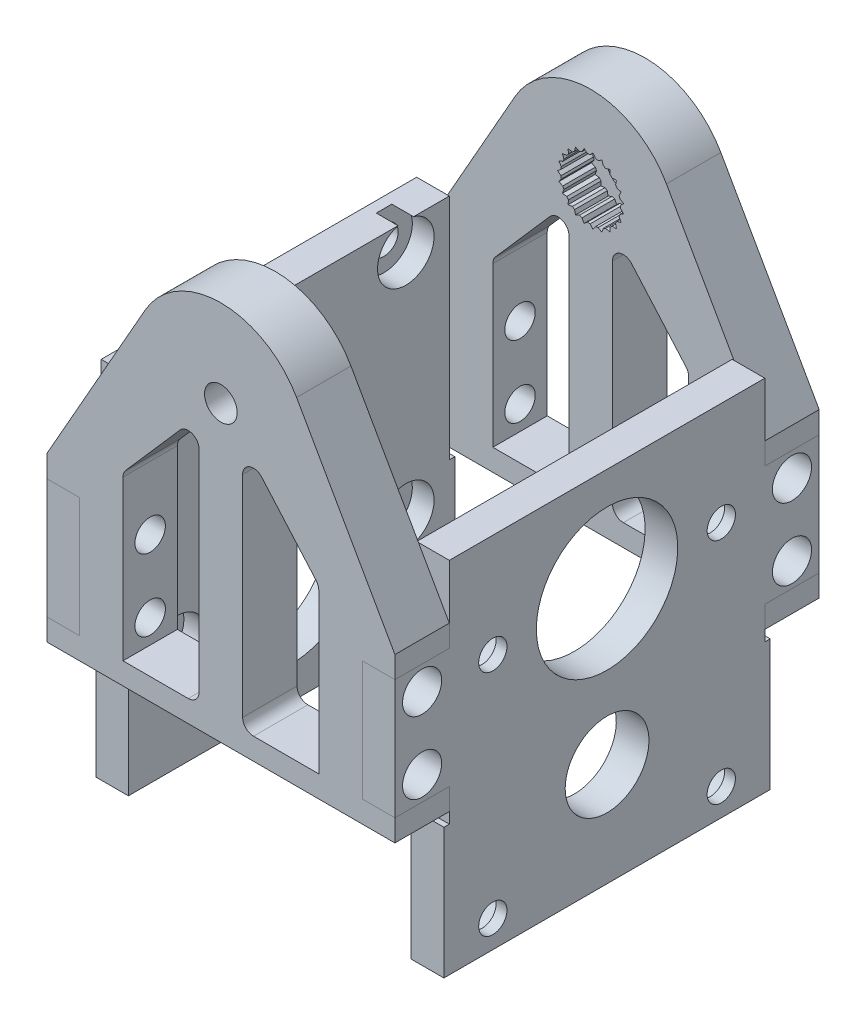
from build123d import *

# Parameters (mm, degrees)
SKETCH_1_R                       = 2.75
EXTRUDE_1_DEPTH                  = 3
CUT_EXTRUDE_6_DEPTH              = 4
EXTRUDE_2_DEPTH                  = 2
SKETCH_3_R                       = 3.6
EXTRUDE_3_DEPTH                  = 1.5
EXTRUDE_4_DEPTH                  = 3.5
SKETCH_5_W                       = 3
SKETCH_5_H                       = 11
CUT_EXTRUDE_1_DEPTH              = 40
SKETCH_6_R                       = 6.5
SKETCH_6_R_2                     = 1.3
SKETCH_6_R_3                     = 3.85
EXTRUDE_5_DEPTH                  = 3
SKETCH_8_R                       = 1.3
SKETCH_8_R_2                     = 6.5
SKETCH_8_R_3                     = 3.85
EXTRUDE_6_DEPTH                  = 3
SKETCH_7_R                       = 1.5
CUT_EXTRUDE_2_DEPTH              = 40
HOLE_WIZARD_2_8_2_8_1_AT_2_COUNT = 2
HOLE_WIZARD_2_8_2_8_1_AT_2_PITCH = 34.634664716
HOLE_WIZARD_2_8_2_8_1_AT_3_COUNT = 2
HOLE_WIZARD_2_8_2_8_1_AT_3_PITCH = 34
HOLE_WIZARD_2_8_2_8_1_AT_4_COUNT = 2
HOLE_WIZARD_2_8_2_8_1_AT_4_PITCH = 6.6
HOLE_WIZARD_2_8_2_8_2_AT_2_COUNT = 2
HOLE_WIZARD_2_8_2_8_2_AT_2_PITCH = 6.6
HOLE_WIZARD_2_8_2_8_2_AT_3_COUNT = 2
HOLE_WIZARD_2_8_2_8_2_AT_3_PITCH = 34
HOLE_WIZARD_2_8_2_8_2_AT_4_COUNT = 2
HOLE_WIZARD_2_8_2_8_2_AT_4_PITCH = 34.634664716
SKETCH_16_W                      = 1.8
SKETCH_16_H                      = 32
HOLE_WIZARD_3_6_3_6_1_AT_2_COUNT = 2
HOLE_WIZARD_3_6_3_6_1_AT_2_PITCH = 6.6
HOLE_WIZARD_3_6_3_6_1_AT_3_COUNT = 2
HOLE_WIZARD_3_6_3_6_1_AT_3_PITCH = 34
HOLE_WIZARD_3_6_3_6_1_AT_4_COUNT = 2
HOLE_WIZARD_3_6_3_6_1_AT_4_PITCH = 34.634664716
SKETCH_17_R                      = 2.6
CUT_EXTRUDE_4_DEPTH              = 2
SKETCH_18_R                      = 2.6
CUT_EXTRUDE_5_DEPTH              = 2
SKETCH_20_W                      = 3
SKETCH_20_H                      = 12
EXTRUDE_7_DEPTH                  = 0.5
SKETCH_21_W                      = 3
SKETCH_21_H                      = 12
EXTRUDE_8_DEPTH                  = 0.5
SKETCH_22_R                      = 4.2
CUT_EXTRUDE_7_DEPTH              = 4


with BuildPart() as part:
    # ｽｹｯﾁ1 → ﾎﾞｽ - 押し出し1 (new body)
    with BuildSketch(Plane.XY):
        with BuildLine():
            Line((-16, -12), (-16, -27))
            Line((-16, -27), (16, -27))
            Line((16, -27), (16, -12))
            Line((16, -12), (6.959272667, 3.94569689))
            ThreePointArc((6.959272667, 3.94569689), (0, 8), (-6.959272667, 3.94569689))
            Line((-6.959272667, 3.94569689), (-16, -12))
        make_face()
        Circle(SKETCH_1_R, mode=Mode.SUBTRACT)
    extrude(amount=EXTRUDE_1_DEPTH)

    # ｽｹｯﾁ19 → ｶｯﾄ - 押し出し6 (cut, through all)
    with BuildSketch(Plane.XY.offset(3)):
        with BuildLine():
            Line((0.208139361, 3.042889746), (-0.062598794, 2.749287433))
            ThreePointArc((-0.062598794, 2.749287433), (0.187666637, 2.743589115), (0.436377003, 2.715156554))
            Line((0.436377003, 2.715156554), (0.208139361, 3.042889746))
        make_face()
        with BuildLine():
            Line((1.021382817, 2.873895812), (0.681471411, 2.66422535))
            ThreePointArc((0.681471411, 2.66422535), (0.920918933, 2.591217536), (1.152735431, 2.496738077))
            Line((1.152735431, 2.496738077), (1.021382817, 2.873895812))
        make_face()
        with BuildLine():
            Line((1.758874982, 2.491758174), (1.375, 2.38156986))
            ThreePointArc((1.375, 2.38156986), (1.585870886, 2.246667206), (1.783600746, 2.093147959))
            Line((1.783600746, 2.093147959), (1.758874982, 2.491758174))
        make_face()
        with BuildLine():
            Line((2.365919437, 1.92481823), (1.966551129, 1.922284229))
            ThreePointArc((1.966551129, 1.922284229), (2.133206049, 1.735491847), (2.282184553, 1.534318633))
            Line((2.282184553, 1.534318633), (2.365919437, 1.92481823))
        make_face()
        with BuildLine():
            Line((2.79749447, 1.215123324), (2.412252157, 1.320431571))
            ThreePointArc((2.412252157, 1.320431571), (2.522331079, 1.095602997), (2.611509172, 0.861695912))
            Line((2.611509172, 0.861695912), (2.79749447, 1.215123324))
        make_face()
        with BuildLine():
            Line((3.021592135, 0.41530828), (2.679047477, 0.620648543))
            ThreePointArc((2.679047477, 0.620648543), (2.724386352, 0.374458285), (2.747150103, 0.125165148))
            Line((2.747150103, 0.125165148), (3.021592135, 0.41530828))
        make_face()
        with BuildLine():
            Line((3.021592135, -0.41530828), (2.747150103, -0.125165148))
            ThreePointArc((2.747150103, -0.125165148), (2.724386352, -0.374458285), (2.679047477, -0.620648543))
            Line((2.679047477, -0.620648543), (3.021592135, -0.41530828))
        make_face()
        with BuildLine():
            Line((2.79749447, -1.215123324), (2.611509172, -0.861695912))
            ThreePointArc((2.611509172, -0.861695912), (2.522331079, -1.095602997), (2.412252157, -1.320431571))
            Line((2.412252157, -1.320431571), (2.79749447, -1.215123324))
        make_face()
        with BuildLine():
            Line((2.365919437, -1.92481823), (2.282184553, -1.534318633))
            ThreePointArc((2.282184553, -1.534318633), (2.133206049, -1.735491847), (1.966551129, -1.922284229))
            Line((1.966551129, -1.922284229), (2.365919437, -1.92481823))
        make_face()
        with BuildLine():
            Line((1.758874982, -2.491758174), (1.783600746, -2.093147959))
            ThreePointArc((1.783600746, -2.093147959), (1.585870886, -2.246667206), (1.375, -2.38156986))
            Line((1.375, -2.38156986), (1.758874982, -2.491758174))
        make_face()
        with BuildLine():
            Line((1.021382817, -2.873895812), (1.152735431, -2.496738077))
            ThreePointArc((1.152735431, -2.496738077), (0.920918933, -2.591217536), (0.681471411, -2.66422535))
            Line((0.681471411, -2.66422535), (1.021382817, -2.873895812))
        make_face()
        with BuildLine():
            Line((0.208139361, -3.042889746), (0.436377003, -2.715156554))
            ThreePointArc((0.436377003, -2.715156554), (0.187666637, -2.743589115), (-0.062598794, -2.749287433))
            Line((-0.062598794, -2.749287433), (0.208139361, -3.042889746))
        make_face()
        with BuildLine():
            Line((-0.62054084, -2.986206467), (-0.312345512, -2.73220429))
            ThreePointArc((-0.312345512, -2.73220429), (-0.559504036, -2.692481241), (-0.802026334, -2.630447445))
            Line((-0.802026334, -2.630447445), (-0.62054084, -2.986206467))
        make_face()
        with BuildLine():
            Line((-1.403198365, -2.708049916), (-1.037902788, -2.546616933))
            ThreePointArc((-1.037902788, -2.546616933), (-1.265178854, -2.441684351), (-1.481971249, -2.316519203))
            Line((-1.481971249, -2.316519203), (-1.403198365, -2.708049916))
        make_face()
        with BuildLine():
            Line((-2.081787087, -2.229049691), (-1.686483563, -2.172158648))
            ThreePointArc((-1.686483563, -2.172158648), (-1.877021144, -2.009798902), (-2.052005136, -1.830785329))
            Line((-2.052005136, -1.830785329), (-2.081787087, -2.229049691))
        make_face()
        with BuildLine():
            Line((-2.605979184, -1.584731048), (-2.209985568, -1.636601293))
            ThreePointArc((-2.209985568, -1.636601293), (-2.349653363, -1.428855863), (-2.46985119, -1.209270483))
            Line((-2.46985119, -1.209270483), (-2.605979184, -1.584731048))
        make_face()
        with BuildLine():
            Line((-2.936897726, -0.822880152), (-2.569583052, -0.979664707))
            ThreePointArc((-2.569583052, -0.979664707), (-2.64802254, -0.741941121), (-2.704519679, -0.498069577))
            Line((-2.704519679, -0.498069577), (-2.936897726, -0.822880152))
        make_face()
        with BuildLine():
            Line((-3.05, 0), (-2.738606317, -0.250070871))
            ThreePointArc((-2.738606317, -0.250070871), (-2.75, 0), (-2.738606317, 0.250070871))
            Line((-2.738606317, 0.250070871), (-3.05, 0))
        make_face()
        with BuildLine():
            Line((-2.936897726, 0.822880152), (-2.704519679, 0.498069577))
            ThreePointArc((-2.704519679, 0.498069577), (-2.64802254, 0.741941121), (-2.569583052, 0.979664707))
            Line((-2.569583052, 0.979664707), (-2.936897726, 0.822880152))
        make_face()
        with BuildLine():
            Line((-2.605979184, 1.584731048), (-2.46985119, 1.209270483))
            ThreePointArc((-2.46985119, 1.209270483), (-2.349653363, 1.428855863), (-2.209985568, 1.636601293))
            Line((-2.209985568, 1.636601293), (-2.605979184, 1.584731048))
        make_face()
        with BuildLine():
            Line((-2.081787087, 2.229049691), (-2.052005136, 1.830785329))
            ThreePointArc((-2.052005136, 1.830785329), (-1.877021144, 2.009798902), (-1.686483563, 2.172158648))
            Line((-1.686483563, 2.172158648), (-2.081787087, 2.229049691))
        make_face()
        with BuildLine():
            Line((-1.403198365, 2.708049916), (-1.481971249, 2.316519203))
            ThreePointArc((-1.481971249, 2.316519203), (-1.265178854, 2.441684351), (-1.037902788, 2.546616933))
            Line((-1.037902788, 2.546616933), (-1.403198365, 2.708049916))
        make_face()
        with BuildLine():
            Line((-0.62054084, 2.986206467), (-0.802026334, 2.630447445))
            ThreePointArc((-0.802026334, 2.630447445), (-0.559504036, 2.692481241), (-0.312345512, 2.73220429))
            Line((-0.312345512, 2.73220429), (-0.62054084, 2.986206467))
        make_face()
    extrude(amount=-CUT_EXTRUDE_6_DEPTH, mode=Mode.SUBTRACT)

    # ｽｹｯﾁ2 → ﾎﾞｽ - 押し出し2 (add)
    with BuildSketch(Plane(origin=(0, 0, 0), x_dir=(-1, 0, 0), z_dir=(0, 0, -1))):
        with BuildLine():
            Line((16, -12), (6.959272667, 3.94569689))
            ThreePointArc((6.959272667, 3.94569689), (0, 8), (-6.959272667, 3.94569689))
            Line((-6.959272667, 3.94569689), (-16, -12))
            Line((-16, -12), (-16, -27))
            Line((-16, -27), (16, -27))
            Line((16, -27), (16, -12))
        make_face()
    extrude(amount=EXTRUDE_2_DEPTH)


with BuildPart() as body_2:
    # ｽｹｯﾁ3 → ﾎﾞｽ - 押し出し3 (new body)
    with BuildSketch(Plane.XY.offset(33.5)):
        with BuildLine():
            Line((-6.959272667, 3.94569689), (-16, -12))
            Line((-16, -12), (-16, -27))
            Line((-16, -27), (16, -27))
            Line((16, -27), (16, -12))
            Line((16, -12), (6.959272667, 3.94569689))
            ThreePointArc((6.959272667, 3.94569689), (0, 8), (-6.959272667, 3.94569689))
        make_face()
        Circle(SKETCH_3_R, mode=Mode.SUBTRACT)
    extrude(amount=-EXTRUDE_3_DEPTH)

    # ｽｹｯﾁ4 → ﾎﾞｽ - 押し出し4 (add)
    with BuildSketch(Plane.XY.offset(33.5)):
        with BuildLine():
            Line((-6.959272667, 3.94569689), (-16, -12))
            Line((-16, -12), (-16, -27))
            Line((-16, -27), (16, -27))
            Line((16, -27), (16, -12))
            Line((16, -12), (6.959272667, 3.94569689))
            ThreePointArc((6.959272667, 3.94569689), (0, 8), (-6.959272667, 3.94569689))
        make_face()
    extrude(amount=EXTRUDE_4_DEPTH)


with BuildPart() as cut_extrude_1_tool:
    # ｽｹｯﾁ5 → ｶｯﾄ - 押し出し1 (new body, through all)
    with BuildSketch(Plane(origin=(0, 0, -2), x_dir=(-1, 0, 0), z_dir=(0, 0, -1))):
        with Locations((-14.5, -19.5)):
            Rectangle(SKETCH_5_W, SKETCH_5_H)
        with Locations((14.5, -19.5)):
            Rectangle(SKETCH_5_W, SKETCH_5_H)
    extrude(amount=-CUT_EXTRUDE_1_DEPTH)


with BuildPart() as part_1:
    add(part.part)

    # ｶｯﾄ - 押し出し1: cut by cut_extrude_1_tool
    add(cut_extrude_1_tool.part, mode=Mode.SUBTRACT)


with BuildPart() as body_2_1:
    add(body_2.part)

    # ｶｯﾄ - 押し出し1: cut by cut_extrude_1_tool
    add(cut_extrude_1_tool.part, mode=Mode.SUBTRACT)


with BuildPart() as body_3:
    # ｽｹｯﾁ6 → ﾎﾞｽ - 押し出し5 (new body)
    with BuildSketch(Plane(origin=(13, 0, 0), x_dir=(0, 0, -1), z_dir=(1, 0, 0))):
        Polygon((2, -14), (-3, -14), (-3, -7), (-32, -7), (-32, -14), (-37, -14), (-37, -25), (-32, -25), (-32, -40), (-3, -40), (-3, -25), (2, -25), align=None)
        with Locations((-17.5, -16.5)):
            Circle(SKETCH_6_R, mode=Mode.SUBTRACT)
        with Locations((-28, -16.5)):
            Circle(SKETCH_6_R_2, mode=Mode.SUBTRACT)
        with Locations((-7, -16.5)):
            Circle(SKETCH_6_R_2, mode=Mode.SUBTRACT)
        with Locations((-28, -37.5)):
            Circle(SKETCH_6_R_2, mode=Mode.SUBTRACT)
        with Locations((-7, -37.5)):
            Circle(SKETCH_6_R_2, mode=Mode.SUBTRACT)
        with Locations((-17.5, -30.5)):
            Circle(SKETCH_6_R_3, mode=Mode.SUBTRACT)
    extrude(amount=EXTRUDE_5_DEPTH)


with BuildPart() as body_4:
    # ｽｹｯﾁ8 → ﾎﾞｽ - 押し出し6 (new body)
    with BuildSketch(Plane.ZY.offset(13)):
        Polygon((-2, -14), (-2, -25), (3, -25), (3, -40), (32, -40), (32, -25), (37, -25), (37, -14), (32, -14), (32, -7), (3, -7), (3, -14), align=None)
        with Locations((28, -9.5)):
            Circle(SKETCH_8_R, mode=Mode.SUBTRACT)
        with Locations((7, -9.5)):
            Circle(SKETCH_8_R, mode=Mode.SUBTRACT)
        with Locations((28, -30.5)):
            Circle(SKETCH_8_R, mode=Mode.SUBTRACT)
        with Locations((17.5, -30.5)):
            Circle(SKETCH_8_R_2, mode=Mode.SUBTRACT)
        with Locations((7, -30.5)):
            Circle(SKETCH_8_R, mode=Mode.SUBTRACT)
        with Locations((17.5, -16.5)):
            Circle(SKETCH_8_R_3, mode=Mode.SUBTRACT)
    extrude(amount=EXTRUDE_6_DEPTH)


with BuildPart() as cut_extrude_2_tool:
    # ｽｹｯﾁ7 → ｶｯﾄ - 押し出し2 (new body, through all)
    with BuildSketch(Plane(origin=(0, 0, -2), x_dir=(-1, 0, 0), z_dir=(0, 0, -1))):
        Circle(SKETCH_7_R)
        with BuildLine():
            Line((-9, -25), (-3, -25))
            ThreePointArc((-3, -25), (-2.292893219, -24.707106781), (-2, -24))
            Line((-2, -24), (-2, -4.661449402))
            ThreePointArc((-2, -4.661449402), (-2.648273327, -3.725346658), (-3.752576695, -4.002944794))
            Line((-3.752576695, -4.002944794), (-8.752576695, -9.717230508))
            ThreePointArc((-8.752576695, -9.717230508), (-8.936102744, -10.024008443), (-9, -10.375735116))
            Line((-9, -10.375735116), (-9, -25))
        make_face()
        with BuildLine():
            Line((9, -25), (3, -25))
            ThreePointArc((3, -25), (2.292893219, -24.707106781), (2, -24))
            Line((2, -24), (2, -4.661449402))
            ThreePointArc((2, -4.661449402), (2.648273327, -3.725346658), (3.752576695, -4.002944794))
            Line((3.752576695, -4.002944794), (8.752576695, -9.717230508))
            ThreePointArc((8.752576695, -9.717230508), (8.936102744, -10.024008443), (9, -10.375735116))
            Line((9, -10.375735116), (9, -25))
        make_face()
    extrude(amount=-CUT_EXTRUDE_2_DEPTH)


with BuildPart() as part_2:
    add(part_1.part)

    # ｶｯﾄ - 押し出し2: cut by cut_extrude_2_tool
    add(cut_extrude_2_tool.part, mode=Mode.SUBTRACT)


with BuildPart() as body_2_2:
    add(body_2_1.part)

    # ｶｯﾄ - 押し出し2: cut by cut_extrude_2_tool
    add(cut_extrude_2_tool.part, mode=Mode.SUBTRACT)


with BuildPart() as hole_wizard_2_8_2_8_1_tool:
    # ｽｹｯﾁ11 → Ø2.8 (2.8) 直径の穴1 (revolve)
    with BuildSketch(Plane(origin=(16, -22.8, 0.5), x_dir=(0, 0, -1), z_dir=(0, 1, 0))):
        Polygon((0, 0), (0, 14), (1.4, 13.158795133), (1.4, 0), align=None)
    hole_wizard_2_8_2_8_1 = revolve(axis=Axis((22.35, -22.8, 0.5), (-1, 0, 0)))


with BuildPart() as part_3:
    add(part_2.part)

    # Ø2.8 (2.8) 直径の穴1: cut by hole_wizard_2_8_2_8_1_tool
    add(hole_wizard_2_8_2_8_1_tool.part, mode=Mode.SUBTRACT)


with BuildPart() as body_3_1:
    add(body_3.part)

    # Ø2.8 (2.8) 直径の穴1: cut by hole_wizard_2_8_2_8_1_tool
    add(hole_wizard_2_8_2_8_1_tool.part, mode=Mode.SUBTRACT)


with BuildPart() as hole_wizard_2_8_2_8_1_at_2_tool:
    # Ø2.8 (2.8) 直径の穴1 at 2: Ø2.8 (2.8) 直径の穴1 ×2
    with Locations(*[Vector(0, 0.190560528, 0.981675448) * (i * HOLE_WIZARD_2_8_2_8_1_AT_2_PITCH) for i in range(1, HOLE_WIZARD_2_8_2_8_1_AT_2_COUNT)]):
        add(hole_wizard_2_8_2_8_1)


with BuildPart() as body_2_3:
    add(body_2_2.part)

    # Ø2.8 (2.8) 直径の穴1 at 2: cut by hole_wizard_2_8_2_8_1_at_2_tool
    add(hole_wizard_2_8_2_8_1_at_2_tool.part, mode=Mode.SUBTRACT)


with BuildPart() as body_3_2:
    add(body_3_1.part)

    # Ø2.8 (2.8) 直径の穴1 at 2: cut by hole_wizard_2_8_2_8_1_at_2_tool
    add(hole_wizard_2_8_2_8_1_at_2_tool.part, mode=Mode.SUBTRACT)


with BuildPart() as hole_wizard_2_8_2_8_1_at_3_tool:
    # Ø2.8 (2.8) 直径の穴1 at 3: Ø2.8 (2.8) 直径の穴1 ×2
    with Locations(*[(0, 0, i * HOLE_WIZARD_2_8_2_8_1_AT_3_PITCH) for i in range(1, HOLE_WIZARD_2_8_2_8_1_AT_3_COUNT)]):
        add(hole_wizard_2_8_2_8_1)


with BuildPart() as body_2_4:
    add(body_2_3.part)

    # Ø2.8 (2.8) 直径の穴1 at 3: cut by hole_wizard_2_8_2_8_1_at_3_tool
    add(hole_wizard_2_8_2_8_1_at_3_tool.part, mode=Mode.SUBTRACT)


with BuildPart() as body_3_3:
    add(body_3_2.part)

    # Ø2.8 (2.8) 直径の穴1 at 3: cut by hole_wizard_2_8_2_8_1_at_3_tool
    add(hole_wizard_2_8_2_8_1_at_3_tool.part, mode=Mode.SUBTRACT)


with BuildPart() as hole_wizard_2_8_2_8_1_at_4_tool:
    # Ø2.8 (2.8) 直径の穴1 at 4: Ø2.8 (2.8) 直径の穴1 ×2
    with Locations(*[(0, i * HOLE_WIZARD_2_8_2_8_1_AT_4_PITCH, 0) for i in range(1, HOLE_WIZARD_2_8_2_8_1_AT_4_COUNT)]):
        add(hole_wizard_2_8_2_8_1)


with BuildPart() as part_4:
    add(part_3.part)

    # Ø2.8 (2.8) 直径の穴1 at 4: cut by hole_wizard_2_8_2_8_1_at_4_tool
    add(hole_wizard_2_8_2_8_1_at_4_tool.part, mode=Mode.SUBTRACT)


with BuildPart() as body_3_4:
    add(body_3_3.part)

    # Ø2.8 (2.8) 直径の穴1 at 4: cut by hole_wizard_2_8_2_8_1_at_4_tool
    add(hole_wizard_2_8_2_8_1_at_4_tool.part, mode=Mode.SUBTRACT)


with BuildPart() as hole_wizard_2_8_2_8_2_tool:
    # ｽｹｯﾁ13 → Ø2.8 (2.8) 直径の穴2 (revolve)
    with BuildSketch(Plane(origin=(-16, -16.2, 34.5), x_dir=(0, 0, 1), z_dir=(0, 1, 0))):
        Polygon((0, 0), (0, 14), (1.4, 13.158795133), (1.4, 0), align=None)
    hole_wizard_2_8_2_8_2 = revolve(axis=Axis((-22.35, -16.2, 34.5), (1, 0, 0)))


with BuildPart() as body_2_5:
    add(body_2_4.part)

    # Ø2.8 (2.8) 直径の穴2: cut by hole_wizard_2_8_2_8_2_tool
    add(hole_wizard_2_8_2_8_2_tool.part, mode=Mode.SUBTRACT)


with BuildPart() as body_4_1:
    add(body_4.part)

    # Ø2.8 (2.8) 直径の穴2: cut by hole_wizard_2_8_2_8_2_tool
    add(hole_wizard_2_8_2_8_2_tool.part, mode=Mode.SUBTRACT)


with BuildPart() as hole_wizard_2_8_2_8_2_at_2_tool:
    # Ø2.8 (2.8) 直径の穴2 at 2: Ø2.8 (2.8) 直径の穴2 ×2
    with Locations(*[(0, -i * HOLE_WIZARD_2_8_2_8_2_AT_2_PITCH, 0) for i in range(1, HOLE_WIZARD_2_8_2_8_2_AT_2_COUNT)]):
        add(hole_wizard_2_8_2_8_2)


with BuildPart() as body_2_6:
    add(body_2_5.part)

    # Ø2.8 (2.8) 直径の穴2 at 2: cut by hole_wizard_2_8_2_8_2_at_2_tool
    add(hole_wizard_2_8_2_8_2_at_2_tool.part, mode=Mode.SUBTRACT)


with BuildPart() as body_4_2:
    add(body_4_1.part)

    # Ø2.8 (2.8) 直径の穴2 at 2: cut by hole_wizard_2_8_2_8_2_at_2_tool
    add(hole_wizard_2_8_2_8_2_at_2_tool.part, mode=Mode.SUBTRACT)


with BuildPart() as hole_wizard_2_8_2_8_2_at_3_tool:
    # Ø2.8 (2.8) 直径の穴2 at 3: Ø2.8 (2.8) 直径の穴2 ×2
    with Locations(*[(0, 0, -i * HOLE_WIZARD_2_8_2_8_2_AT_3_PITCH) for i in range(1, HOLE_WIZARD_2_8_2_8_2_AT_3_COUNT)]):
        add(hole_wizard_2_8_2_8_2)


with BuildPart() as part_5:
    add(part_4.part)

    # Ø2.8 (2.8) 直径の穴2 at 3: cut by hole_wizard_2_8_2_8_2_at_3_tool
    add(hole_wizard_2_8_2_8_2_at_3_tool.part, mode=Mode.SUBTRACT)


with BuildPart() as body_4_3:
    add(body_4_2.part)

    # Ø2.8 (2.8) 直径の穴2 at 3: cut by hole_wizard_2_8_2_8_2_at_3_tool
    add(hole_wizard_2_8_2_8_2_at_3_tool.part, mode=Mode.SUBTRACT)


with BuildPart() as hole_wizard_2_8_2_8_2_at_4_tool:
    # Ø2.8 (2.8) 直径の穴2 at 4: Ø2.8 (2.8) 直径の穴2 ×2
    with Locations(*[Vector(0, -0.190560528, -0.981675448) * (i * HOLE_WIZARD_2_8_2_8_2_AT_4_PITCH) for i in range(1, HOLE_WIZARD_2_8_2_8_2_AT_4_COUNT)]):
        add(hole_wizard_2_8_2_8_2)


with BuildPart() as part_6:
    add(part_5.part)

    # Ø2.8 (2.8) 直径の穴2 at 4: cut by hole_wizard_2_8_2_8_2_at_4_tool
    add(hole_wizard_2_8_2_8_2_at_4_tool.part, mode=Mode.SUBTRACT)


with BuildPart() as body_4_4:
    add(body_4_3.part)

    # Ø2.8 (2.8) 直径の穴2 at 4: cut by hole_wizard_2_8_2_8_2_at_4_tool
    add(hole_wizard_2_8_2_8_2_at_4_tool.part, mode=Mode.SUBTRACT)


with BuildPart() as hole_wizard_3_6_3_6_1_tool:
    # ｽｹｯﾁ16 → Ø3.6 (3.6) 直径の穴1 (revolve)
    with BuildSketch(Plane(origin=(16, -16.2, 34.5), x_dir=(0, 0, -1), z_dir=(0, 1, 0))):
        with Locations((0.9, 16)):
            Rectangle(SKETCH_16_W, SKETCH_16_H)
    hole_wizard_3_6_3_6_1 = revolve(axis=Axis((22.35, -16.2, 34.5), (-1, 0, 0)))


with BuildPart() as body_3_5:
    add(body_3_4.part)

    # Ø3.6 (3.6) 直径の穴1: cut by hole_wizard_3_6_3_6_1_tool
    add(hole_wizard_3_6_3_6_1_tool.part, mode=Mode.SUBTRACT)


with BuildPart() as body_4_5:
    add(body_4_4.part)

    # Ø3.6 (3.6) 直径の穴1: cut by hole_wizard_3_6_3_6_1_tool
    add(hole_wizard_3_6_3_6_1_tool.part, mode=Mode.SUBTRACT)


with BuildPart() as hole_wizard_3_6_3_6_1_at_2_tool:
    # Ø3.6 (3.6) 直径の穴1 at 2: Ø3.6 (3.6) 直径の穴1 ×2
    with Locations(*[(0, -i * HOLE_WIZARD_3_6_3_6_1_AT_2_PITCH, 0) for i in range(1, HOLE_WIZARD_3_6_3_6_1_AT_2_COUNT)]):
        add(hole_wizard_3_6_3_6_1)


with BuildPart() as body_3_6:
    add(body_3_5.part)

    # Ø3.6 (3.6) 直径の穴1 at 2: cut by hole_wizard_3_6_3_6_1_at_2_tool
    add(hole_wizard_3_6_3_6_1_at_2_tool.part, mode=Mode.SUBTRACT)


with BuildPart() as body_4_6:
    add(body_4_5.part)

    # Ø3.6 (3.6) 直径の穴1 at 2: cut by hole_wizard_3_6_3_6_1_at_2_tool
    add(hole_wizard_3_6_3_6_1_at_2_tool.part, mode=Mode.SUBTRACT)


with BuildPart() as hole_wizard_3_6_3_6_1_at_3_tool:
    # Ø3.6 (3.6) 直径の穴1 at 3: Ø3.6 (3.6) 直径の穴1 ×2
    with Locations(*[(0, 0, -i * HOLE_WIZARD_3_6_3_6_1_AT_3_PITCH) for i in range(1, HOLE_WIZARD_3_6_3_6_1_AT_3_COUNT)]):
        add(hole_wizard_3_6_3_6_1)


with BuildPart() as body_3_7:
    add(body_3_6.part)

    # Ø3.6 (3.6) 直径の穴1 at 3: cut by hole_wizard_3_6_3_6_1_at_3_tool
    add(hole_wizard_3_6_3_6_1_at_3_tool.part, mode=Mode.SUBTRACT)


with BuildPart() as body_4_7:
    add(body_4_6.part)

    # Ø3.6 (3.6) 直径の穴1 at 3: cut by hole_wizard_3_6_3_6_1_at_3_tool
    add(hole_wizard_3_6_3_6_1_at_3_tool.part, mode=Mode.SUBTRACT)


with BuildPart() as hole_wizard_3_6_3_6_1_at_4_tool:
    # Ø3.6 (3.6) 直径の穴1 at 4: Ø3.6 (3.6) 直径の穴1 ×2
    with Locations(*[Vector(0, -0.190560528, -0.981675448) * (i * HOLE_WIZARD_3_6_3_6_1_AT_4_PITCH) for i in range(1, HOLE_WIZARD_3_6_3_6_1_AT_4_COUNT)]):
        add(hole_wizard_3_6_3_6_1)


with BuildPart() as body_3_8:
    add(body_3_7.part)

    # Ø3.6 (3.6) 直径の穴1 at 4: cut by hole_wizard_3_6_3_6_1_at_4_tool
    add(hole_wizard_3_6_3_6_1_at_4_tool.part, mode=Mode.SUBTRACT)

    # ｽｹｯﾁ17 → ｶｯﾄ - 押し出し4 (cut)
    with BuildSketch(Plane.ZY.offset(-13)):
        with Locations((7, -16.5)):
            Circle(SKETCH_17_R)
        with Locations((7, -37.5)):
            Circle(SKETCH_17_R)
        with Locations((28, -37.5)):
            Circle(SKETCH_17_R)
        with Locations((28, -16.5)):
            Circle(SKETCH_17_R)
    extrude(amount=-CUT_EXTRUDE_4_DEPTH, mode=Mode.SUBTRACT)



with BuildPart() as body_4_8:
    add(body_4_7.part)

    # Ø3.6 (3.6) 直径の穴1 at 4: cut by hole_wizard_3_6_3_6_1_at_4_tool
    add(hole_wizard_3_6_3_6_1_at_4_tool.part, mode=Mode.SUBTRACT)

    # ｽｹｯﾁ18 → ｶｯﾄ - 押し出し5 (cut)
    with BuildSketch(Plane(origin=(-13, 0, 0), x_dir=(0, 0, -1), z_dir=(1, 0, 0))):
        with Locations((-28, -9.5)):
            Circle(SKETCH_18_R)
        with Locations((-28, -30.5)):
            Circle(SKETCH_18_R)
        with Locations((-7, -30.5)):
            Circle(SKETCH_18_R)
        with Locations((-7, -9.5)):
            Circle(SKETCH_18_R)
    extrude(amount=-CUT_EXTRUDE_5_DEPTH, mode=Mode.SUBTRACT)


with BuildPart() as body_3_9:
    add(body_3_8.part)

    add(body_4_8.part)  # ﾎﾞｽ - 押し出し7 merges body 4
    # ｽｹｯﾁ20 → ﾎﾞｽ - 押し出し7 (add)
    with BuildSketch(Plane.XY.offset(32)):
        with Locations((-14.5, -34)):
            Rectangle(SKETCH_20_W, SKETCH_20_H)
        with Locations((14.5, -34)):
            Rectangle(SKETCH_20_W, SKETCH_20_H)
    extrude(amount=EXTRUDE_7_DEPTH)

    # ｽｹｯﾁ21 → ﾎﾞｽ - 押し出し8 (add)
    with BuildSketch(Plane(origin=(0, 0, 3), x_dir=(-1, 0, 0), z_dir=(0, 0, -1))):
        with Locations((-14.5, -34)):
            Rectangle(SKETCH_21_W, SKETCH_21_H)
        with Locations((14.5, -34)):
            Rectangle(SKETCH_21_W, SKETCH_21_H)
    extrude(amount=EXTRUDE_8_DEPTH)

    # ｽｹｯﾁ22 → ｶｯﾄ - 押し出し7 (cut, through all)
    with BuildSketch(Plane(origin=(-13, 0, 0), x_dir=(0, 0, -1), z_dir=(1, 0, 0))):
        with Locations((-17.5, -16.5)):
            Circle(SKETCH_22_R)
    extrude(amount=-CUT_EXTRUDE_7_DEPTH, mode=Mode.SUBTRACT)


solid = Compound([body_2_6.part, part_6.part, body_3_9.part])
